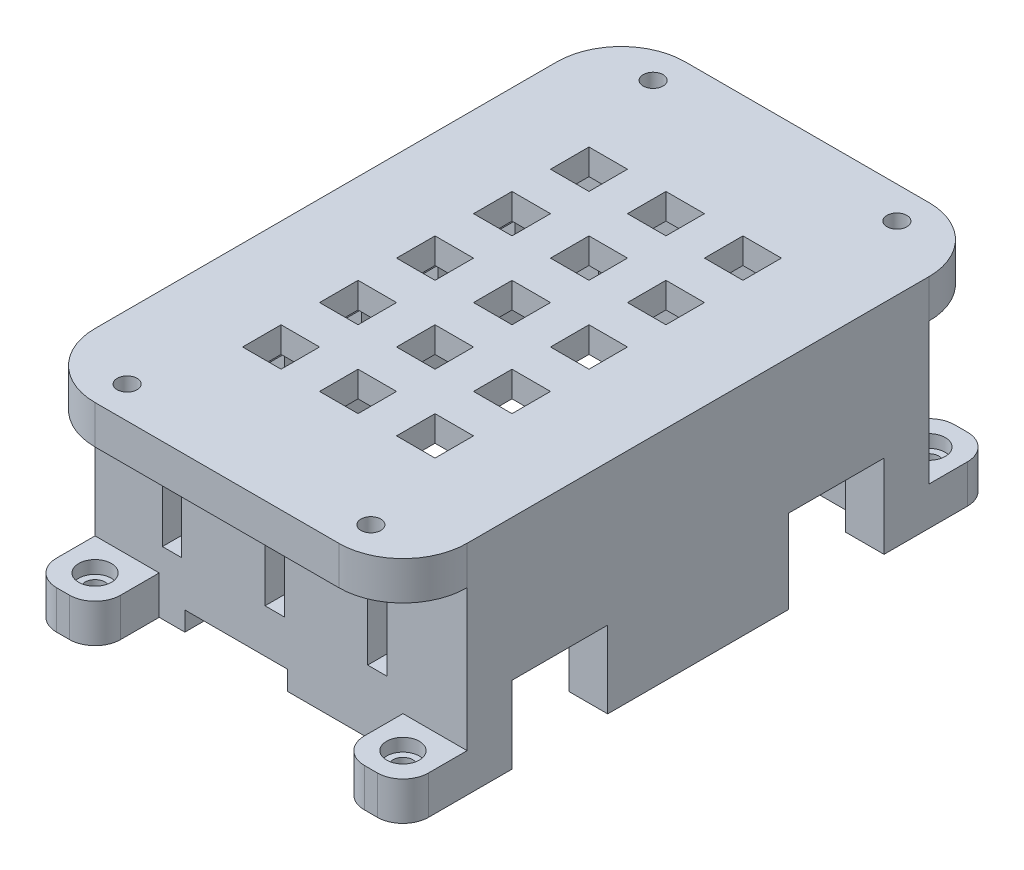
from build123d import *

# Parameters (mm, degrees)
SKETCH1_W           = 25
SKETCH1_H           = 32
BOSS_EXTRUDE1_DEPTH = 2
SKETCH2_W           = 29
SKETCH2_H           = 36
SKETCH2_W_2         = 25
SKETCH2_H_2         = 32
BOSS_EXTRUDE2_DEPTH = 17
SKETCH3_W           = 18
SKETCH3_H           = 2
CUT_EXTRUDE1_DEPTH  = 2.7
SKETCH4_W           = 8
SKETCH4_H           = 2
CUT_EXTRUDE2_DEPTH  = 1.5
SKETCH7_W           = 1
SKETCH7_H           = 32
BOSS_EXTRUDE3_DEPTH = 15
SKETCH8_W           = 3
SKETCH8_H           = 7.46
CUT_EXTRUDE4_DEPTH  = 6
SKETCH9_W           = 3
SKETCH9_H           = 7.46
CUT_EXTRUDE5_DEPTH  = 6.5
SKETCH10_W          = 29
SKETCH10_H          = 3
BOSS_EXTRUDE4_DEPTH = 5
SKETCH11_W          = 29
SKETCH11_H          = 3
BOSS_EXTRUDE5_DEPTH = 5
SKETCH12_R          = 0.775
CUT_EXTRUDE6_DEPTH  = 4
FILLET1_R           = 5
SKETCH13_R          = 1.275
CUT_EXTRUDE7_DEPTH  = 1
SKETCH14_W          = 5
SKETCH14_H          = 3
BOSS_EXTRUDE6_DEPTH = 5
SKETCH15_W          = 5
SKETCH15_H          = 3
BOSS_EXTRUDE7_DEPTH = 5
SKETCH16_R          = 0.775
CUT_EXTRUDE8_DEPTH  = 5
FILLET2_R           = 2
SKETCH17_R          = 1.275
CUT_EXTRUDE9_DEPTH  = 1
SKETCH18_W          = 1.5
SKETCH18_H          = 5
CUT_EXTRUDE10_DEPTH = 42
SKETCH19_W          = 3
SKETCH19_H          = 3
CUT_EXTRUDE11_DEPTH = 18
SKETCH21_W          = 1.5
SKETCH21_H          = 5
CUT_EXTRUDE12_DEPTH = 2


with BuildPart() as part:
    # Sketch1 → Boss-Extrude1 (new body)
    with BuildSketch(Plane(origin=(0, 0, 0), x_dir=(1, 0, 0), z_dir=(0, 1, 0))):
        with Locations((-1.021545319, 9.369242199)):
            Rectangle(SKETCH1_W, SKETCH1_H)
    extrude(amount=BOSS_EXTRUDE1_DEPTH)

    # Sketch2 → Boss-Extrude2 (add)
    with BuildSketch(Plane(origin=(0, 2, 0), x_dir=(1, 0, 0), z_dir=(0, 1, 0))):
        with Locations((-1.021545319, 9.369242199)):
            Rectangle(SKETCH2_W, SKETCH2_H)
        with Locations((-1.021545319, 9.369242199)):
            Rectangle(SKETCH2_W_2, SKETCH2_H_2, mode=Mode.SUBTRACT)
    extrude(amount=-BOSS_EXTRUDE2_DEPTH)

    # Sketch3 → Cut-Extrude1 (cut)
    with BuildSketch(Plane.XZ.offset(15)):
        with Locations((-4.521545319, -26.369242199)):
            Rectangle(SKETCH3_W, SKETCH3_H)
    extrude(amount=-CUT_EXTRUDE1_DEPTH, mode=Mode.SUBTRACT)

    # Sketch4 → Cut-Extrude2 (cut)
    with BuildSketch(Plane.XZ.offset(15)):
        with Locations((-4.521545319, 7.630757801)):
            Rectangle(SKETCH4_W, SKETCH4_H)
    extrude(amount=-CUT_EXTRUDE2_DEPTH, mode=Mode.SUBTRACT)

    # Sketch7 → Boss-Extrude3 (add)
    with BuildSketch(Plane.XZ):
        with Locations((10.978454681, -9.369242199)):
            Rectangle(SKETCH7_W, SKETCH7_H)
    extrude(amount=BOSS_EXTRUDE3_DEPTH)

    # Sketch8 → Cut-Extrude4 (cut)
    with BuildSketch(Plane.XZ.offset(15)):
        with Locations((11.978454681, 1.400757801)):
            Rectangle(SKETCH8_W, SKETCH8_H)
    extrude(amount=-CUT_EXTRUDE4_DEPTH, mode=Mode.SUBTRACT)

    # Sketch9 → Cut-Extrude5 (cut)
    with BuildSketch(Plane.XZ.offset(15)):
        with Locations((11.978454681, -20.139242199)):
            Rectangle(SKETCH9_W, SKETCH9_H)
    extrude(amount=-CUT_EXTRUDE5_DEPTH, mode=Mode.SUBTRACT)

    # Sketch10 → Boss-Extrude4 (add)
    with BuildSketch(Plane.XY.offset(8.630757801)):
        with Locations((-1.021545319, 0.5)):
            Rectangle(SKETCH10_W, SKETCH10_H)
    extrude(amount=BOSS_EXTRUDE4_DEPTH)

    # Sketch11 → Boss-Extrude5 (add)
    with BuildSketch(Plane(origin=(0, 0, -27.369242199), x_dir=(-1, 0, 0), z_dir=(0, 0, -1))):
        with Locations((1.021545319, 0.5)):
            Rectangle(SKETCH11_W, SKETCH11_H)
    extrude(amount=BOSS_EXTRUDE5_DEPTH)

    # Sketch12 → Cut-Extrude6 (cut, through all)
    with BuildSketch(Plane.XZ.offset(1)):
        with Locations((-10.521545319, 11.130757801)):
            Circle(SKETCH12_R)
        with Locations((8.478454681, 11.130757801)):
            Circle(SKETCH12_R)
        with Locations((8.478454681, -29.869242199)):
            Circle(SKETCH12_R)
        with Locations((-10.521545319, -29.869242199)):
            Circle(SKETCH12_R)
    extrude(amount=-CUT_EXTRUDE6_DEPTH, mode=Mode.SUBTRACT)

    # Fillet1
    fillet1_edges = [part.edges().sort_by_distance(p)[0] for p in [
        (-15.521545319, 0.5, -32.369242199),
        (13.478454681, 0.5, -32.369242199),
        (13.478454681, 0.5, 13.630757801),
        (-15.521545319, 0.5, 13.630757801),
    ]]
    fillet(fillet1_edges, radius=FILLET1_R)

    # Sketch13 → Cut-Extrude7 (cut)
    with BuildSketch(Plane.XZ.offset(1)):
        with Locations((8.478454681, -29.869242199)):
            Circle(SKETCH13_R)
        with Locations((-10.521545319, -29.869242199)):
            Circle(SKETCH13_R)
        with Locations((8.478454681, 11.130757801)):
            Circle(SKETCH13_R)
        with Locations((-10.521545319, 11.130757801)):
            Circle(SKETCH13_R)
    extrude(amount=-CUT_EXTRUDE7_DEPTH, mode=Mode.SUBTRACT)

    # Sketch14 → Boss-Extrude6 (add)
    with BuildSketch(Plane.XY.offset(8.630757801)):
        with Locations((-13.021545319, -13.5)):
            Rectangle(SKETCH14_W, SKETCH14_H)
        with Locations((10.978454681, -13.5)):
            Rectangle(SKETCH14_W, SKETCH14_H)
    extrude(amount=BOSS_EXTRUDE6_DEPTH)

    # Sketch15 → Boss-Extrude7 (add)
    with BuildSketch(Plane(origin=(0, 0, -27.369242199), x_dir=(-1, 0, 0), z_dir=(0, 0, -1))):
        with Locations((-10.978454681, -13.5)):
            Rectangle(SKETCH15_W, SKETCH15_H)
    extrude(amount=BOSS_EXTRUDE7_DEPTH)

    # Sketch16 → Cut-Extrude8 (cut)
    with BuildSketch(Plane.XZ.offset(15)):
        with Locations((10.978454681, 11.130757801)):
            Circle(SKETCH16_R)
        with Locations((-13.021545319, 11.130757801)):
            Circle(SKETCH16_R)
        with Locations((10.978454681, -29.869242199)):
            Circle(SKETCH16_R)
    extrude(amount=-CUT_EXTRUDE8_DEPTH, mode=Mode.SUBTRACT)

    # Fillet2
    fillet2_edges = [part.edges().sort_by_distance(p)[0] for p in [
        (-15.521545319, -13.5, 13.630757801),
        (-10.521545319, -13.5, 13.630757801),
        (13.478454681, -13.5, 13.630757801),
        (8.478454681, -13.5, 13.630757801),
        (13.478454681, -13.5, -32.369242199),
        (8.478454681, -13.5, -32.369242199),
    ]]
    fillet(fillet2_edges, radius=FILLET2_R)

    # Sketch17 → Cut-Extrude9 (cut)
    with BuildSketch(Plane(origin=(0, -12, 0), x_dir=(1, 0, 0), z_dir=(0, 1, 0))):
        with Locations((10.978454681, -11.130757801)):
            Circle(SKETCH17_R)
        with Locations((-13.021545319, -11.130757801)):
            Circle(SKETCH17_R)
        with Locations((10.978454681, 29.869242199)):
            Circle(SKETCH17_R)
    extrude(amount=-CUT_EXTRUDE9_DEPTH, mode=Mode.SUBTRACT)

    # Sketch18 → Cut-Extrude10 (cut, through all)
    with BuildSketch(Plane.XY.offset(8.630757801)):
        with Locations((-1.521545319, -7.596891606)):
            Rectangle(SKETCH18_W, SKETCH18_H)
        with Locations((6.478454681, -7.596891606)):
            Rectangle(SKETCH18_W, SKETCH18_H)
        with Locations((-9.521545319, -7.596891606)):
            Rectangle(SKETCH18_W, SKETCH18_H)
    extrude(amount=-CUT_EXTRUDE10_DEPTH, mode=Mode.SUBTRACT)

    # Sketch19 → Cut-Extrude11 (cut, through all)
    with BuildSketch(Plane(origin=(0, 2, 0), x_dir=(1, 0, 0), z_dir=(0, 1, 0))):
        with Locations((-1.021545319, 21.369242199)):
            Rectangle(SKETCH19_W, SKETCH19_H)
        with Locations((-7.021545319, 21.369242199)):
            Rectangle(SKETCH19_W, SKETCH19_H)
        with Locations((4.978454681, 21.369242199)):
            Rectangle(SKETCH19_W, SKETCH19_H)
        with Locations((-1.021545319, 15.369242199)):
            Rectangle(SKETCH19_W, SKETCH19_H)
        with Locations((4.978454681, 15.369242199)):
            Rectangle(SKETCH19_W, SKETCH19_H)
        with Locations((-1.021545319, 9.369242199)):
            Rectangle(SKETCH19_W, SKETCH19_H)
        with Locations((4.978454681, 9.369242199)):
            Rectangle(SKETCH19_W, SKETCH19_H)
        with Locations((-1.021545319, 3.369242199)):
            Rectangle(SKETCH19_W, SKETCH19_H)
        with Locations((4.978454681, 3.369242199)):
            Rectangle(SKETCH19_W, SKETCH19_H)
        with Locations((-1.021545319, -2.630757801)):
            Rectangle(SKETCH19_W, SKETCH19_H)
        with Locations((4.978454681, -2.630757801)):
            Rectangle(SKETCH19_W, SKETCH19_H)
        with Locations((-7.021545319, 15.369242199)):
            Rectangle(SKETCH19_W, SKETCH19_H)
        with Locations((-7.021545319, 9.369242199)):
            Rectangle(SKETCH19_W, SKETCH19_H)
        with Locations((-7.021545319, 3.369242199)):
            Rectangle(SKETCH19_W, SKETCH19_H)
        with Locations((-7.021545319, -2.630757801)):
            Rectangle(SKETCH19_W, SKETCH19_H)
    extrude(amount=-CUT_EXTRUDE11_DEPTH, mode=Mode.SUBTRACT)

    # Sketch21 → Cut-Extrude12 (cut)
    with BuildSketch(Plane.ZY.offset(15.521545319)):
        with Locations((2.630757801, -7.6)):
            Rectangle(SKETCH21_W, SKETCH21_H)
        with Locations((-3.369242199, -7.6)):
            Rectangle(SKETCH21_W, SKETCH21_H)
        with Locations((-9.369242199, -7.6)):
            Rectangle(SKETCH21_W, SKETCH21_H)
        with Locations((-15.369242199, -7.6)):
            Rectangle(SKETCH21_W, SKETCH21_H)
        with Locations((-21.369242199, -7.6)):
            Rectangle(SKETCH21_W, SKETCH21_H)
    extrude(amount=-CUT_EXTRUDE12_DEPTH, mode=Mode.SUBTRACT)


solid = part.part
